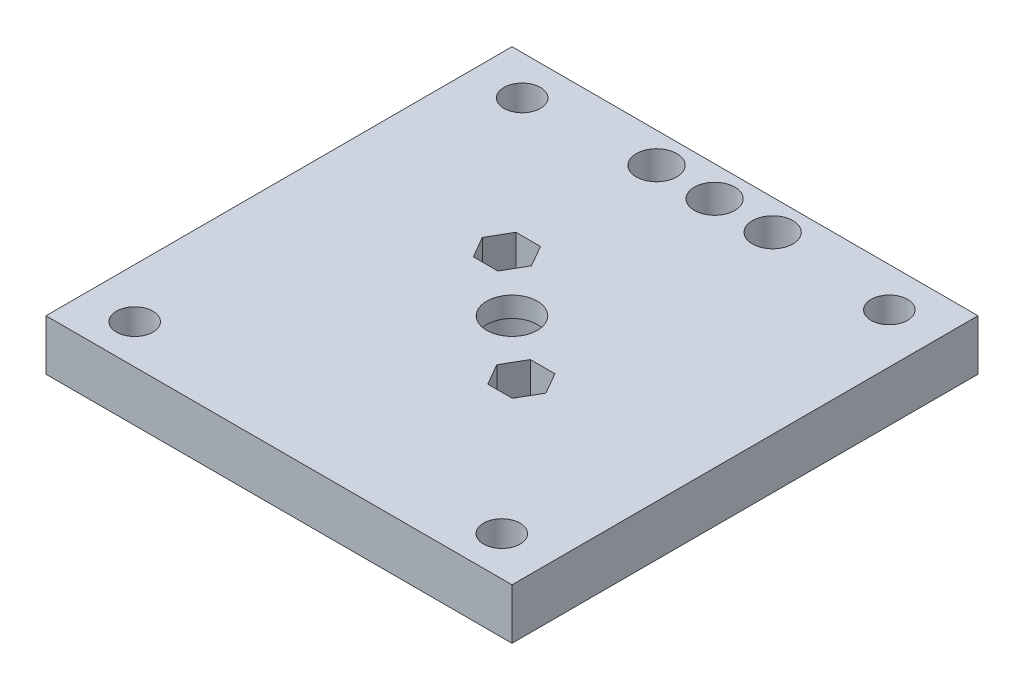
from build123d import *

# Parameters (mm, degrees)
SKETCH2_W           = 46
SKETCH2_H           = 46
BOSS_EXTRUDE1_DEPTH = 5
SKETCH3_R           = 1.8
SKETCH3_R_2         = 2.5
CUT_EXTRUDE1_DEPTH  = 5
SKETCH4_R           = 4.1
CUT_EXTRUDE2_DEPTH  = 3
SKETCH5_W           = 4
SKETCH5_H           = 4
BOSS_EXTRUDE2_DEPTH = 3
SKETCH6_R           = 1
CUT_EXTRUDE3_DEPTH  = 9
CUT_EXTRUDE5_DEPTH  = 4
SKETCH9_R           = 2
CUT_EXTRUDE6_DEPTH  = 6


with BuildPart() as part:
    # Sketch2 → Boss-Extrude1 (new body)
    with BuildSketch(Plane(origin=(0, 0, 0), x_dir=(1, 0, 0), z_dir=(0, 1, 0))):
        Rectangle(SKETCH2_W, SKETCH2_H)
    extrude(amount=BOSS_EXTRUDE1_DEPTH)

    # Sketch3 → Cut-Extrude1 (cut)
    with BuildSketch(Plane(origin=(0, 0, 0), x_dir=(1, 0, 0), z_dir=(0, 1, 0))):
        with Locations((-18.12, 19.125)):
            Circle(SKETCH3_R)
        with Locations((18.12, 19.125)):
            Circle(SKETCH3_R)
        with Locations((18.12, -19.125)):
            Circle(SKETCH3_R)
        with Locations((-18.12, -19.125)):
            Circle(SKETCH3_R)
        Circle(SKETCH3_R_2)
    extrude(amount=CUT_EXTRUDE1_DEPTH, mode=Mode.SUBTRACT)

    # Sketch4 → Cut-Extrude2 (cut)
    with BuildSketch(Plane(origin=(0, 0, 0), x_dir=(1, 0, 0), z_dir=(0, 1, 0))):
        Circle(SKETCH4_R)
    extrude(amount=CUT_EXTRUDE2_DEPTH, mode=Mode.SUBTRACT)

    # Sketch5 → Boss-Extrude2 (add)
    with BuildSketch(Plane(origin=(0, 0, 0), x_dir=(1, 0, 0), z_dir=(0, 1, 0))):
        with Locations((-5.7330026, 5.06948708)):
            Rectangle(SKETCH5_W, SKETCH5_H)
        with Locations((5.862376563, -4.939727226)):
            Rectangle(SKETCH5_W, SKETCH5_H)
    extrude(amount=-BOSS_EXTRUDE2_DEPTH)

    # Sketch6 → Cut-Extrude3 (cut, through all)
    with BuildSketch(Plane(origin=(0, -3, 0), x_dir=(-1, 0, 0), z_dir=(0, -1, 0))):
        with Locations((5.7330026, 5.230811807)):
            Circle(SKETCH6_R)
        with Locations((-5.862376563, -4.939727226)):
            Circle(SKETCH6_R)
    extrude(amount=-CUT_EXTRUDE3_DEPTH, mode=Mode.SUBTRACT)

    # Sketch8 → Cut-Extrude5 (cut)
    with BuildSketch(Plane(origin=(0, 5, 0), x_dir=(1, 0, 0), z_dir=(0, 1, 0))):
        Polygon((8.287247693, -4.939727226), (7.074812128, -2.839727226), (4.649940998, -2.839727226), (3.437505432, -4.939727226), (4.649940998, -7.039727226), (7.074812128, -7.039727226), align=None)
        Polygon((-3.30813147, 5.230811807), (-4.520567035, 7.330811807), (-6.945438166, 7.330811807), (-8.157873731, 5.230811807), (-6.945438166, 3.130811807), (-4.520567035, 3.130811807), align=None)
    extrude(amount=-CUT_EXTRUDE5_DEPTH, mode=Mode.SUBTRACT)

    # Sketch9 → Cut-Extrude6 (cut, through all)
    with BuildSketch(Plane(origin=(0, 0, 0), x_dir=(1, 0, 0), z_dir=(0, 1, 0))):
        with Locations((-5.7330026, 20)):
            Circle(SKETCH9_R)
        with Locations((5.73, 20)):
            Circle(SKETCH9_R)
        with Locations((0, 20)):
            Circle(SKETCH9_R)
    extrude(amount=CUT_EXTRUDE6_DEPTH, mode=Mode.SUBTRACT)


solid = part.part
